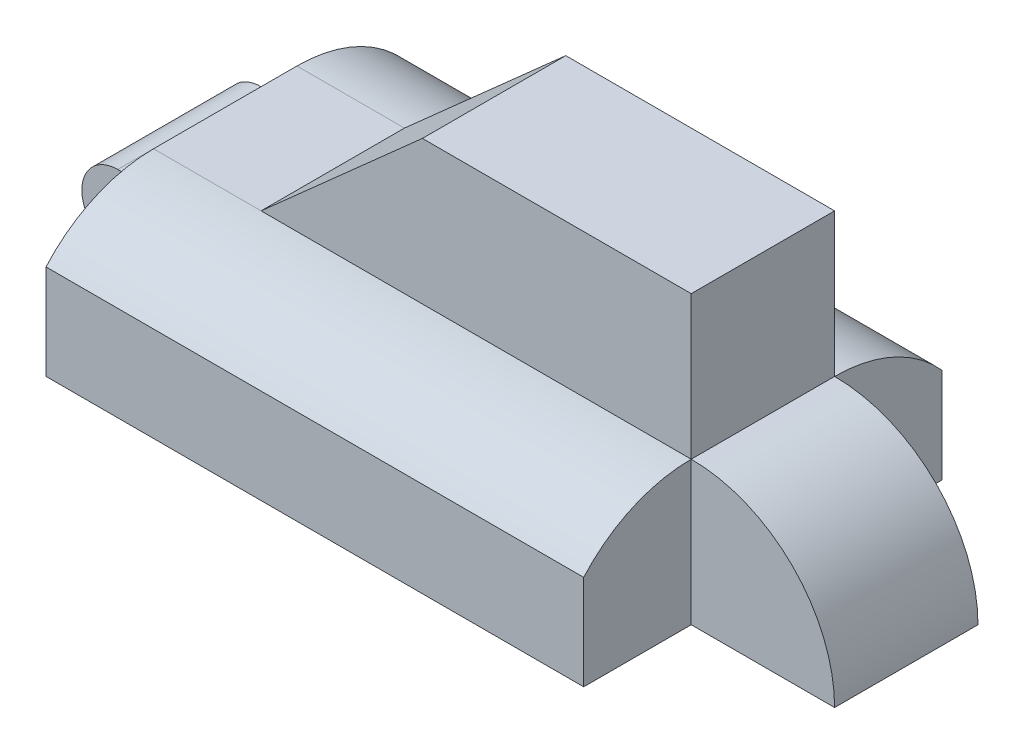
from build123d import *

# Parameters (mm, degrees)
SKETCH1_W           = 95.25
SKETCH1_H           = 63.5
BOSS_EXTRUDE1_DEPTH = 25.4
SKETCH2_W           = 76.2
SKETCH2_H           = 25.4
BOSS_EXTRUDE2_DEPTH = 25.4
CUT_EXTRUDE1_DEPTH  = 25.4
SKETCH4_W           = 25.4
SKETCH4_H           = 25.4
BOSS_EXTRUDE3_DEPTH = 25.4
CUT_EXTRUDE2_DEPTH  = 25.4
CUT_EXTRUDE3_DEPTH  = 95.25
SKETCH_1648_W       = 25.4
SKETCH_1648_H       = 12.7
BOSS_EXTRUDE4_DEPTH = 12.7
CUT_EXTRUDE4_DEPTH  = 25.4
SKETCH10_R          = 2.54
CUT_EXTRUDE5_DEPTH  = 25.4
SCALE1_SCALE        = 0.5


with BuildPart() as part:
    # Sketch1 → Boss-Extrude1 (new body)
    with BuildSketch(Plane(origin=(0, 0, 0), x_dir=(1, 0, 0), z_dir=(0, 1, 0))):
        Rectangle(SKETCH1_W, SKETCH1_H)
    extrude(amount=BOSS_EXTRUDE1_DEPTH)

    # Sketch2 → Boss-Extrude2 (add)
    with BuildSketch(Plane(origin=(0, 25.4, 0), x_dir=(1, 0, 0), z_dir=(0, 1, 0))):
        with Locations((9.525, 0)):
            Rectangle(SKETCH2_W, SKETCH2_H)
    extrude(amount=BOSS_EXTRUDE2_DEPTH)

    # Sketch3 → Cut-Extrude1 (cut)
    with BuildSketch(Plane.XY.offset(12.7)):
        Polygon((-28.575, 50.8), (-28.575, 25.4), (0, 50.8), align=None)
    extrude(amount=-CUT_EXTRUDE1_DEPTH, mode=Mode.SUBTRACT)

    # Sketch4 → Boss-Extrude3 (add)
    with BuildSketch(Plane(origin=(47.625, 0, 0), x_dir=(0, 0, -1), z_dir=(1, 0, 0))):
        with Locations((0, 12.7)):
            Rectangle(SKETCH4_W, SKETCH4_H)
    extrude(amount=BOSS_EXTRUDE3_DEPTH)

    # Sketch5 → Cut-Extrude2 (cut)
    with BuildSketch(Plane(origin=(0, 0, -12.7), x_dir=(-1, 0, 0), z_dir=(0, 0, -1))):
        with BuildLine():
            ThreePointArc((-47.625, 25.4), (-65.585512242, 17.960512242), (-73.025, 0))
            Line((-73.025, 0), (-73.025, 25.4))
            Line((-73.025, 25.4), (-47.625, 25.4))
        make_face()
    extrude(amount=-CUT_EXTRUDE2_DEPTH, mode=Mode.SUBTRACT)

    # Sketch7 → Cut-Extrude3 (cut)
    with BuildSketch(Plane(origin=(47.625, 0, 0), x_dir=(0, 0, -1), z_dir=(1, 0, 0))):
        with BuildLine():
            Line((-31.75, 16.800520825), (-31.75, 25.4))
            Line((-31.75, 25.4), (-12.7, 25.4))
            ThreePointArc((-12.7, 25.4), (-23.150520825, 23.150520825), (-31.75, 16.800520825))
        make_face()
        with BuildLine():
            Line((12.7, 25.4), (31.75, 25.4))
            Line((31.75, 25.4), (31.75, 16.800520825))
            ThreePointArc((31.75, 16.800520825), (23.150520825, 23.150520825), (12.7, 25.4))
        make_face()
    extrude(amount=-CUT_EXTRUDE3_DEPTH, mode=Mode.SUBTRACT)

    # Sketch 1648 → Boss-Extrude4 (add)
    with BuildSketch(Plane.ZY.offset(47.625)):
        with Locations((0, 12.7)):
            Rectangle(SKETCH_1648_W, SKETCH_1648_H)
    extrude(amount=BOSS_EXTRUDE4_DEPTH)

    # Sketch9 → Cut-Extrude4 (cut)
    with BuildSketch(Plane.XY.offset(12.7)):
        with BuildLine():
            ThreePointArc((-53.975, 6.35), (-58.465128061, 8.209871939), (-60.325, 12.7))
            Line((-60.325, 12.7), (-60.325, 6.35))
            Line((-60.325, 6.35), (-53.975, 6.35))
        make_face()
        with BuildLine():
            Line((-60.325, 19.05), (-60.325, 12.7))
            ThreePointArc((-60.325, 12.7), (-58.465128061, 17.190128061), (-53.975, 19.05))
            Line((-53.975, 19.05), (-60.325, 19.05))
        make_face()
    extrude(amount=-CUT_EXTRUDE4_DEPTH, mode=Mode.SUBTRACT)

    # Sketch10 → Cut-Extrude5 (cut)
    with BuildSketch(Plane.XY.offset(12.7)):
        with Locations((-53.975, 12.7)):
            Circle(SKETCH10_R)
    extrude(amount=-CUT_EXTRUDE5_DEPTH, mode=Mode.SUBTRACT)


with BuildPart() as part_1:
    # Scale1: scaled about (6.140340788, 16.964715806, 0)
    add(part.part.scale(SCALE1_SCALE).moved(Location((3.070170394, 8.482357903, 0))))


solid = part_1.part
